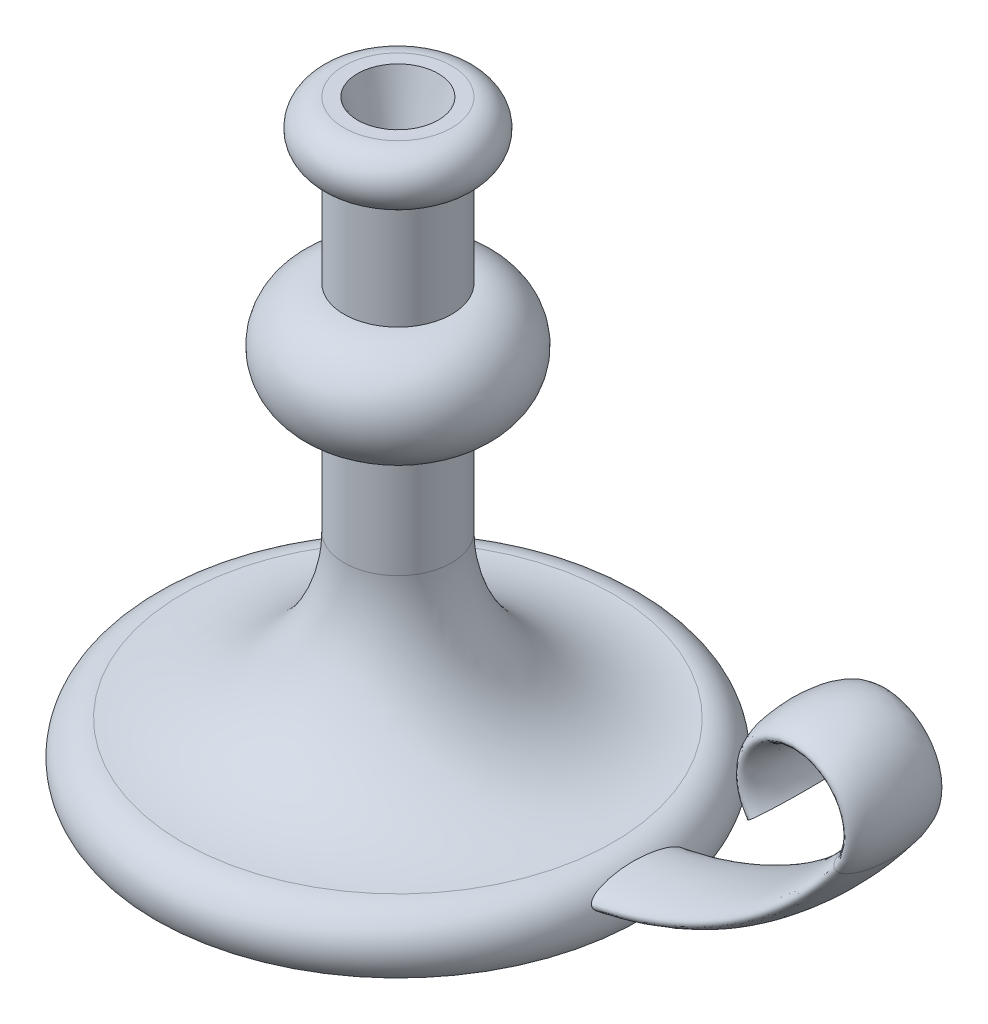
from build123d import *

# Parameters (mm, degrees)
SZKIC3_RX                  = 17.5
SZKIC3_RY                  = 5
SZKIC4_R                   = 15
WYTNIJ_WYCI_GNI_CIE1_DEPTH = 25
WYTNIJ_WYCI_GNI_CIE1_TAPER = 15


with BuildPart() as part:
    # Szkic1 → Obrót1 (revolve)
    with BuildSketch(Plane.XY):
        with BuildLine():
            Line((0, 0), (0, 220))
            Line((0, 220), (20, 220))
            ThreePointArc((20, 220), (30, 210), (20, 200))
            Line((20, 200), (20, 160))
            ThreePointArc((20, 160), (40, 140), (20, 120))
            Line((20, 120), (20, 80))
            ThreePointArc((20, 80), (37.573593129, 37.573593129), (80, 20))
            ThreePointArc((80, 20), (91.180339887, 13.090169944), (90, 0))
            Line((90, 0), (0, 0))
        make_face()
    revolve(axis=Axis((0, 0, 0), (0, 1, 0)))

    # Wyciągnięcie po ścieżce1: sweep along a path in Szkic2
    with BuildLine(Plane.XY) as wyci_gni_cie_po_cie_ce1_path:
        Line((0, 10), (60, 10))
        ThreePointArc((60, 10), (127.082039325, 25.83592135), (180, 70))
        ThreePointArc((180, 70), (164, 102), (148, 70))
    # Szkic3 → Wyciągnięcie po ścieżce1 (sweep)
    with BuildSketch(Plane(origin=(0, 0, 0), x_dir=(0, 0, -1), z_dir=(1, 0, 0))):
        with Locations((0, 10)):
            Ellipse(SZKIC3_RX, SZKIC3_RY)
    sweep(path=wyci_gni_cie_po_cie_ce1_path.line)

    # Szkic4 → Wytnij-wyciągnięcie1 (cut)
    with BuildSketch(Plane(origin=(0, 220, 0), x_dir=(1, 0, 0), z_dir=(0, 1, 0))):
        Circle(SZKIC4_R)
    extrude(amount=-WYTNIJ_WYCI_GNI_CIE1_DEPTH, taper=WYTNIJ_WYCI_GNI_CIE1_TAPER, mode=Mode.SUBTRACT)


solid = part.part
